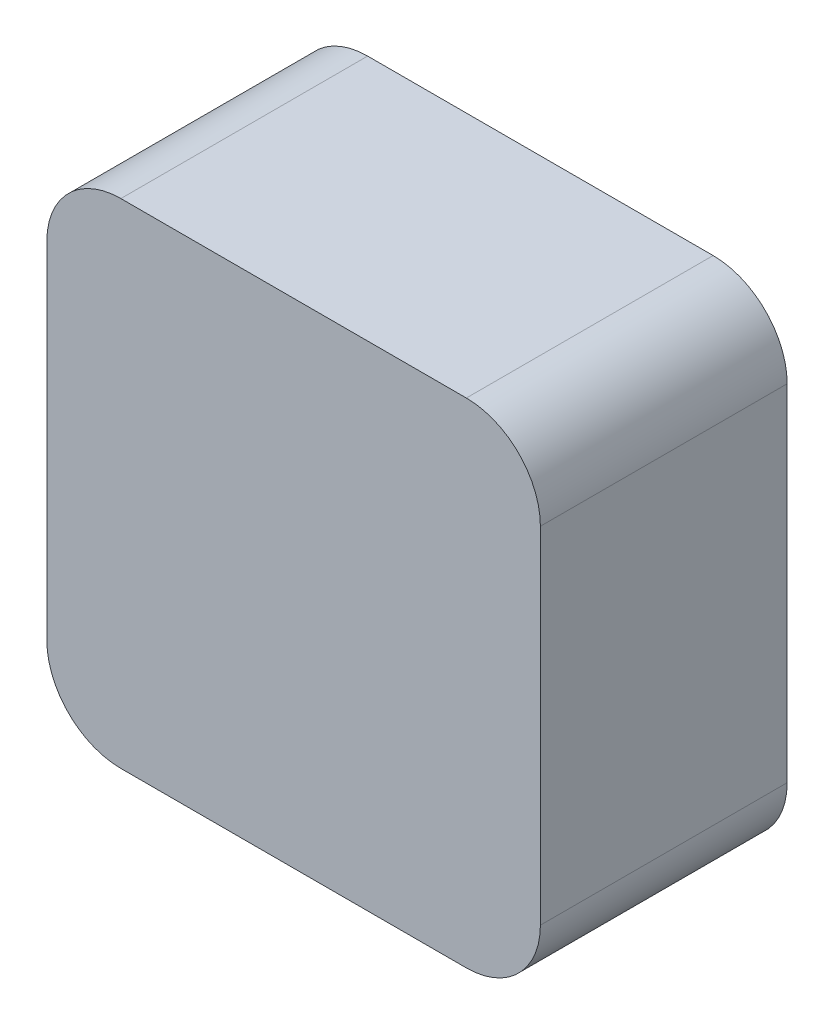
from build123d import *

# Parameters (mm, degrees)
SKETCH1_W           = 10
SKETCH1_H           = 10
SKETCH1_R           = 1.5
BOSS_EXTRUDE1_DEPTH = 5
FILLET1_R           = 1.5
SKETCH2_R           = 1.6
BOSS_EXTRUDE2_DEPTH = 1
SKETCH3_R           = 2.25
CUT_EXTRUDE1_DEPTH  = 4


with BuildPart() as part:
    # Sketch1 → Boss-Extrude1 (new body)
    with BuildSketch(Plane.XY):
        with Locations((-140, 155.5)):
            Rectangle(SKETCH1_W, SKETCH1_H)
        with Locations((-140, 155.5)):
            Circle(SKETCH1_R, mode=Mode.SUBTRACT)
    extrude(amount=BOSS_EXTRUDE1_DEPTH)

    # Fillet1
    fillet1_edges = [part.edges().sort_by_distance(p)[0] for p in [
        (-145, 160.5, 2.5),
        (-135, 160.5, 2.5),
        (-135, 150.5, 2.5),
        (-145, 150.5, 2.5),
    ]]
    fillet(fillet1_edges, radius=FILLET1_R)

    # Sketch2 → Boss-Extrude2 (add)
    with BuildSketch(Plane.XY.offset(5)):
        with Locations((-140, 155.5)):
            Circle(SKETCH2_R)
    extrude(amount=-BOSS_EXTRUDE2_DEPTH)

    # Sketch3 → Cut-Extrude1 (cut)
    with BuildSketch(Plane(origin=(0, 0, 0), x_dir=(-1, 0, 0), z_dir=(0, 0, -1))):
        with Locations((140, 155.5)):
            Circle(SKETCH3_R)
    extrude(amount=-CUT_EXTRUDE1_DEPTH, mode=Mode.SUBTRACT)


solid = part.part
